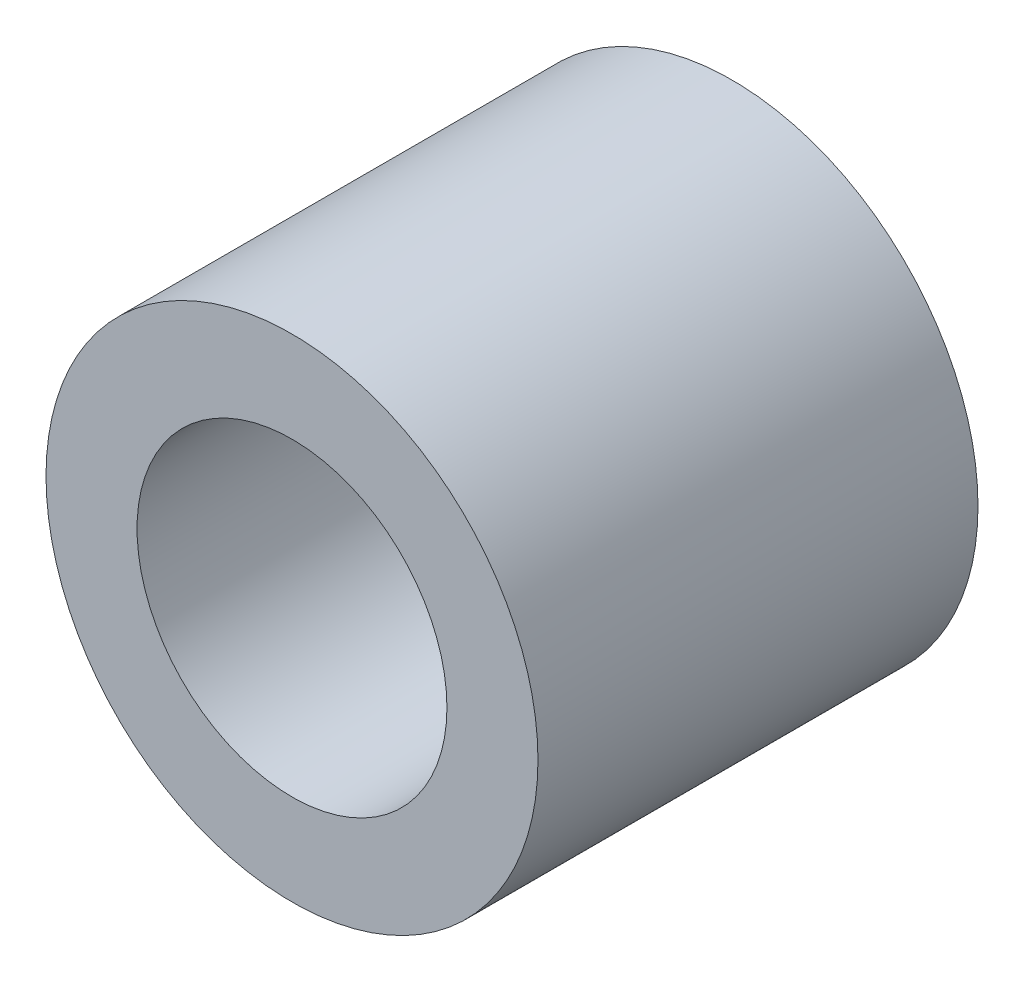
from build123d import *

# Parameters (mm, degrees)
SKETCH1_R           = 2.54
SKETCH1_R_2         = 1.6
BOSS_EXTRUDE1_DEPTH = 2.271749965


with BuildPart() as part:
    # Sketch1 → Boss-Extrude1 (new body, symmetric)
    with BuildSketch(Plane.XY):
        Circle(SKETCH1_R)
        Circle(SKETCH1_R_2, mode=Mode.SUBTRACT)
    extrude(amount=BOSS_EXTRUDE1_DEPTH, both=True)


solid = part.part
